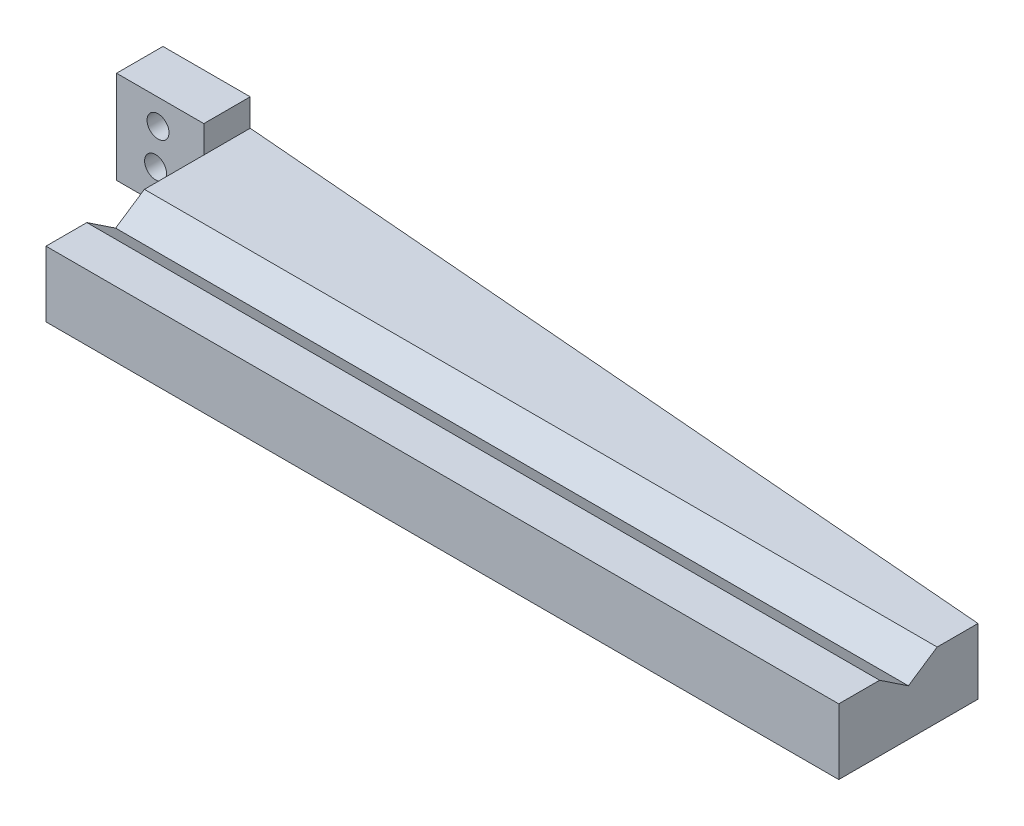
from build123d import *

# Parameters (mm, degrees)
BOSS_EXTRUDE1_DEPTH = 6.35
SKETCH2_W           = 5.588
SKETCH2_H           = 2.624659965
BOSS_EXTRUDE2_DEPTH = 108.458
SKETCH3_W           = 11.938
SKETCH3_H           = 6.35
BOSS_EXTRUDE3_DEPTH = 6.35
SKETCH4_R           = 1.5
CUT_EXTRUDE1_DEPTH  = 6.35
SKETCH5_W           = 24.200861289
SKETCH5_H           = 43.914531272
CUT_EXTRUDE2_DEPTH  = 6.35
BOSS_EXTRUDE8_DEPTH = 12.7
SKETCH7_R           = 1.5
CUT_EXTRUDE3_DEPTH  = 33.02
SKETCH8_W           = 11.938
SKETCH8_H           = 6.35
CUT_EXTRUDE4_DEPTH  = 33.02
CUT_EXTRUDE5_DEPTH  = 3.72534


with BuildPart() as part:
    # Sketch1 → Boss-Extrude1 (new body)
    with BuildSketch(Plane(origin=(0, 0, 0), x_dir=(1, 0, 0), z_dir=(0, 1, 0))):
        Polygon((0, 0), (0, 12.7), (11.938, 12.7), (11.938, 19.05), (-108.458, 19.05), (-108.458, 0), align=None)
    boss_extrude1 = extrude(amount=BOSS_EXTRUDE1_DEPTH)

    # Sketch2 → Boss-Extrude2 (add)
    with BuildSketch(Plane.ZY.offset(108.458)):
        with Locations((-2.794, 7.662329983)):
            Rectangle(SKETCH2_W, SKETCH2_H)
        with Locations((-16.256, 7.662329983)):
            Rectangle(SKETCH2_W, SKETCH2_H)
        Polygon((-5.588, 8.974659965), (-9.525, 6.35), (-5.588, 6.35), align=None)
        Polygon((-13.462, 6.35), (-9.525, 6.35), (-13.462, 8.974659965), align=None)
    extrude(amount=-BOSS_EXTRUDE2_DEPTH)

    # Sketch3 → Boss-Extrude3 (add)
    with BuildSketch(Plane(origin=(0, 6.35, 0), x_dir=(1, 0, 0), z_dir=(0, 1, 0))):
        with Locations((5.969, 15.875)):
            Rectangle(SKETCH3_W, SKETCH3_H)
    boss_extrude3 = extrude(amount=BOSS_EXTRUDE3_DEPTH)

    # Sketch4 → Cut-Extrude1 (cut)
    with BuildSketch(Plane(origin=(0, 0, -19.05), x_dir=(-1, 0, 0), z_dir=(0, 0, -1))):
        with Locations((-6.599652977, 4.237288993)):
            Circle(SKETCH4_R)
        with Locations((-6.263550513, 9.234799649)):
            Circle(SKETCH4_R)
    cut_extrude1 = extrude(amount=-CUT_EXTRUDE1_DEPTH, mode=Mode.SUBTRACT)

    # Mirror1: Boss-Extrude1, Boss-Extrude3, Cut-Extrude1 across plane
    add(boss_extrude1.mirror(Plane.ZY.offset(54.229)))
    add(boss_extrude3.mirror(Plane.ZY.offset(54.229)))
    add(cut_extrude1.mirror(Plane.ZY.offset(54.229)), mode=Mode.SUBTRACT)

    # Sketch5 → Cut-Extrude2 (cut)
    with BuildSketch(Plane(origin=(0, 0, -19.05), x_dir=(-1, 0, 0), z_dir=(0, 0, -1))):
        with Locations((-12.100430645, -9.257265636)):
            Rectangle(SKETCH5_W, SKETCH5_H)
    extrude(amount=-CUT_EXTRUDE2_DEPTH, mode=Mode.SUBTRACT)

    # Sketch6 → Boss-Extrude8 (add)
    with BuildSketch(Plane.XZ):
        Polygon((-108.458, -19.05), (-108.458, -21.59), (-120.396, -21.59), (-120.396, -27.94), (-108.458, -27.94), (0, -19.05), (0, -16.677943068), (-108.458, -16.677943068), align=None)
    extrude(amount=-BOSS_EXTRUDE8_DEPTH)

    # Sketch7 → Cut-Extrude3 (cut)
    with BuildSketch(Plane(origin=(0, 0, -27.94), x_dir=(-1, 0, 0), z_dir=(0, 0, -1))):
        with Locations((114.721550513, 9.234799649)):
            Circle(SKETCH7_R)
        with Locations((115.057652977, 4.237288993)):
            Circle(SKETCH7_R)
    extrude(amount=-CUT_EXTRUDE3_DEPTH, mode=Mode.SUBTRACT)

    # Sketch8 → Cut-Extrude4 (cut)
    with BuildSketch(Plane(origin=(0, 12.7, 0), x_dir=(1, 0, 0), z_dir=(0, 1, 0))):
        with Locations((-114.427, 15.875)):
            Rectangle(SKETCH8_W, SKETCH8_H)
    extrude(amount=-CUT_EXTRUDE4_DEPTH, mode=Mode.SUBTRACT)

    # Sketch9 → Cut-Extrude5 (cut)
    with BuildSketch(Plane(origin=(0, 12.7, 0), x_dir=(1, 0, 0), z_dir=(0, 1, 0))):
        Polygon((-108.458, 27.94), (-108.458, 21.59), (-108.458, 16.677943068), (0, 16.677943068), (0, 19.05), align=None)
    extrude(amount=-CUT_EXTRUDE5_DEPTH, mode=Mode.SUBTRACT)


solid = part.part
